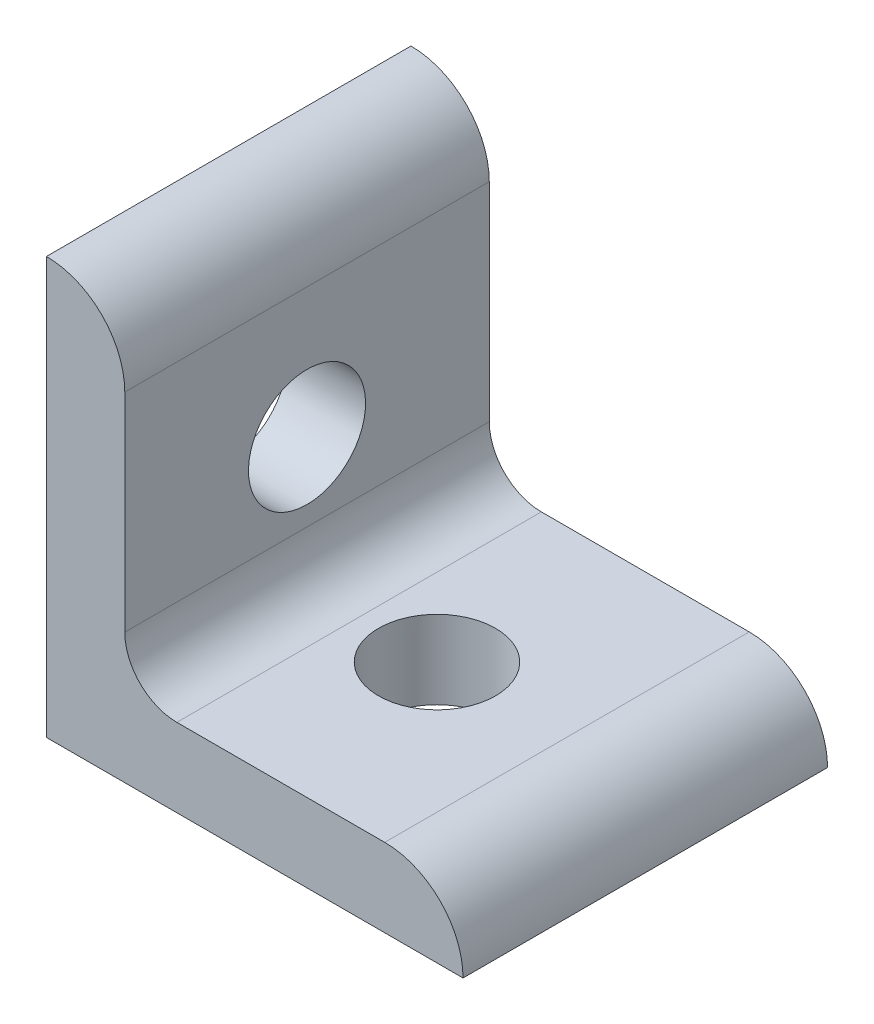
from build123d import *

# Parameters (mm, degrees)
BOSS_EXTRUDE1_DEPTH = 11.1125
SKETCH2_R           = 3.5687
CUT_EXTRUDE1_DEPTH  = 26.4
SKETCH3_R           = 3.5687
CUT_EXTRUDE2_DEPTH  = 26.4


with BuildPart() as part:
    # Sketch1 → Boss-Extrude1 (new body, symmetric)
    with BuildSketch(Plane.XY):
        with BuildLine():
            Line((0, 0), (0, 25.4))
            ThreePointArc((0, 25.4), (3.376576302, 24.001376302), (4.7752, 20.6248))
            Line((4.7752, 20.6248), (4.7752, 7.9502))
            ThreePointArc((4.7752, 7.9502), (5.70513597, 5.70513597), (7.9502, 4.7752))
            Line((7.9502, 4.7752), (20.6248, 4.7752))
            ThreePointArc((20.6248, 4.7752), (24.001376302, 3.376576302), (25.4, 0))
            Line((25.4, 0), (0, 0))
        make_face()
    extrude(amount=BOSS_EXTRUDE1_DEPTH, both=True)

    # Sketch2 → Cut-Extrude1 (cut, through all)
    with BuildSketch(Plane(origin=(0, 0, 0), x_dir=(1, 0, 0), z_dir=(0, 1, 0))):
        with Locations((12.7, 0)):
            Circle(SKETCH2_R)
    extrude(amount=CUT_EXTRUDE1_DEPTH, mode=Mode.SUBTRACT)

    # Sketch3 → Cut-Extrude2 (cut, through all)
    with BuildSketch(Plane(origin=(0, 0, 0), x_dir=(0, 0, -1), z_dir=(1, 0, 0))):
        with Locations((0, 12.7)):
            Circle(SKETCH3_R)
    extrude(amount=CUT_EXTRUDE2_DEPTH, mode=Mode.SUBTRACT)


solid = part.part
